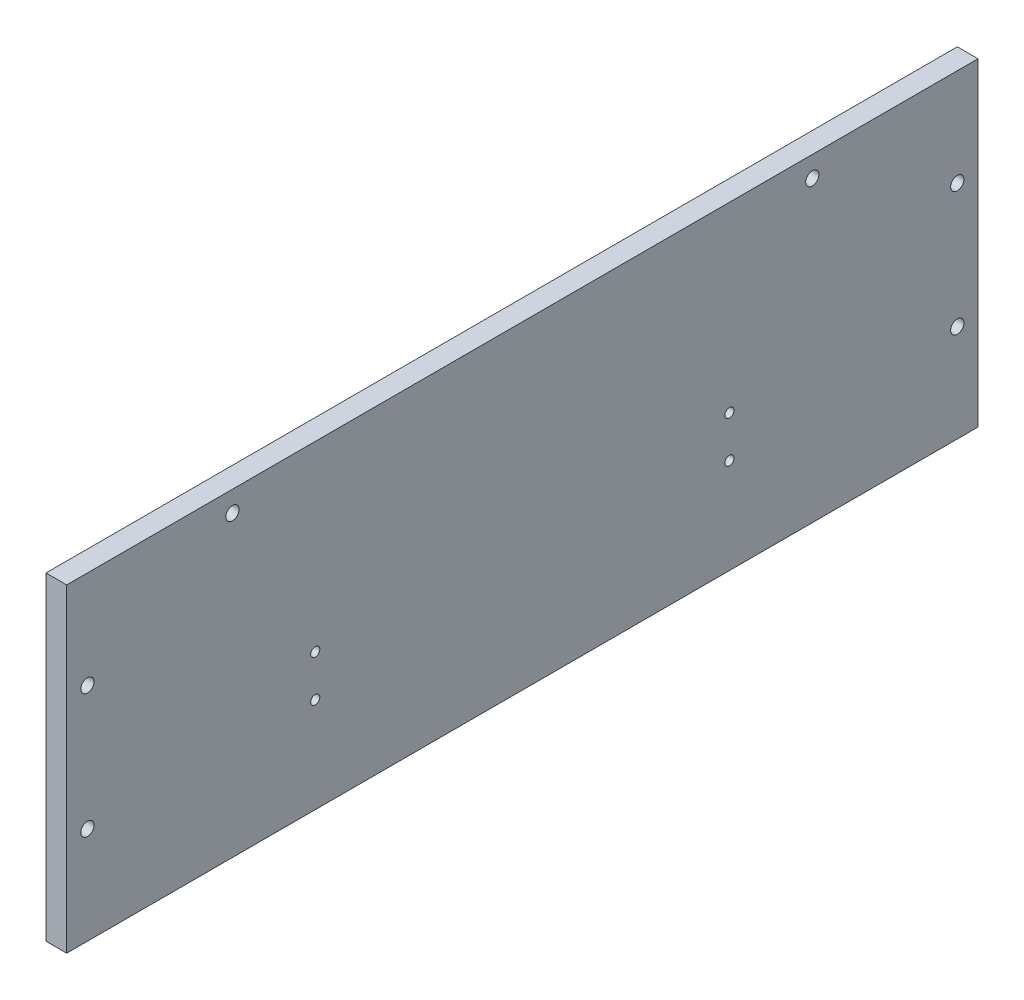
from build123d import *

# Parameters (mm, degrees)
SKETCH1_W                  = 5
SKETCH1_H                  = 110
BOSS_EXTRUDE1_DEPTH        = 120
BOSS_EXTRUDE1_DEPTH_BACK   = 110
BOSS_EXTRUDE1_2_DEPTH      = 120
BOSS_EXTRUDE1_2_DEPTH_BACK = 110
SKETCH2_W                  = 5
SKETCH2_H                  = 37
BOSS_EXTRUDE2_DEPTH        = 50
SKETCH3_W                  = 220
SKETCH3_H                  = 5
BOSS_EXTRUDE3_DEPTH        = 50
SKETCH4_W                  = 230
SKETCH4_H                  = 73
BOSS_EXTRUDE6_DEPTH        = 5
CUT_EXTRUDE3_DEPTH         = 231
SKETCH5_W                  = 348
SKETCH5_H                  = 227
SKETCH5_W_2                = 328
SKETCH5_H_2                = 207
BOSS_EXTRUDE7_DEPTH        = 5
BOSS_EXTRUDE8_DEPTH        = 59
FILLET5_R                  = 15
BOSS_EXTRUDE9_DEPTH        = 5
BOSS_EXTRUDE10_DEPTH       = 5
FILLET6_R                  = 3
SKETCH14_W                 = 102.087252512
SKETCH14_H                 = 394.36321675
CUT_EXTRUDE4_DEPTH         = 165.048773235
CUT_EXTRUDE7_DEPTH         = 6
SKETCH17_R                 = 1.1
HOLES_FOR_PART_4_DEPTH     = 6
SKETCH18_R                 = 1.6
CUT_EXTRUDE9_DEPTH         = 6


with BuildPart() as part:
    # Sketch1 → Boss-Extrude1 (new body, two sides)
    with BuildSketch(Plane(origin=(0, 0, 0), x_dir=(0, 0, -1), z_dir=(1, 0, 0))) as boss_extrude1_sk:
        with Locations((-112.5, 55)):
            Rectangle(SKETCH1_W, SKETCH1_H)
    extrude(amount=BOSS_EXTRUDE1_DEPTH)
    extrude(boss_extrude1_sk.sketch, amount=-BOSS_EXTRUDE1_DEPTH_BACK)



with BuildPart() as body_2:
    # Sketch1 → Boss-Extrude1 2 (new body, two sides)
    with BuildSketch(Plane(origin=(0, 0, 0), x_dir=(0, 0, -1), z_dir=(1, 0, 0))) as boss_extrude1_2_sk:
        with Locations((112.5, 55)):
            Rectangle(SKETCH1_W, SKETCH1_H)
    extrude(amount=BOSS_EXTRUDE1_2_DEPTH)
    extrude(boss_extrude1_2_sk.sketch, amount=-BOSS_EXTRUDE1_2_DEPTH_BACK)


with BuildPart() as part_1:
    add(part.part)

    add(body_2.part)  # Boss-Extrude2 merges body 2
    # Sketch2 → Boss-Extrude2 (add)
    with BuildSketch(Plane.ZY.offset(110)):
        with Locations((-112.5, 18.5)):
            Rectangle(SKETCH2_W, SKETCH2_H)
        with Locations((112.5, 18.5)):
            Rectangle(SKETCH2_W, SKETCH2_H)
    extrude(amount=BOSS_EXTRUDE2_DEPTH)

    # Sketch3 → Boss-Extrude3 (add)
    with BuildSketch(Plane.ZY.offset(160)):
        with Locations((0, 34.5)):
            Rectangle(SKETCH3_W, SKETCH3_H)
    extrude(amount=-BOSS_EXTRUDE3_DEPTH)

    # Sketch4 → Boss-Extrude6 (add)
    with BuildSketch(Plane.ZY.offset(110)):
        with Locations((0, 73.5)):
            Rectangle(SKETCH4_W, SKETCH4_H)
    extrude(amount=BOSS_EXTRUDE6_DEPTH)

    # Sketch9 → Cut-Extrude3 (cut, through all)
    with BuildSketch(Plane.XY.offset(115)):
        Polygon((120, 110), (116.464466094, 106.464466094), (120, 102.928932188), align=None)
    extrude(amount=-CUT_EXTRUDE3_DEPTH, mode=Mode.SUBTRACT)

    # Sketch10 → Boss-Extrude8 (add)
    with BuildSketch(Plane.XY.offset(115)):
        Polygon((120, 110), (111.464466094, 110), (111.464466094, 0), (120, 0), (120, 102.928932188), (116.464466094, 106.464466094), align=None)
    boss_extrude8 = extrude(amount=BOSS_EXTRUDE8_DEPTH)

    # Mirror3: Boss-Extrude8 across plane
    add(boss_extrude8.mirror(Plane.XY))

    # Fillet5
    fillet5_edges = [part_1.edges().sort_by_distance(p)[0] for p in [
        (111.464466094, 55, 115),
        (111.464466094, 55, -115),
    ]]
    fillet(fillet5_edges, radius=FILLET5_R)

    # Fillet6
    fillet6_edges = [part_1.edges().sort_by_distance(p)[0] for p in [
        (111.464466094, 55, 174),
        (111.464466094, 55, -174),
    ]]
    fillet(fillet6_edges, radius=FILLET6_R)


with BuildPart() as body_2_2:
    # Sketch5 → Boss-Extrude7 (new body)
    with BuildSketch(Plane(origin=(115, 115, 0), x_dir=(0, 0, 1), z_dir=(-0.707106781, -0.707106781, 0))):
        with Locations((0, -120.571067812)):
            Rectangle(SKETCH5_W, SKETCH5_H)
        with Locations((0, -120.571067812)):
            Rectangle(SKETCH5_W_2, SKETCH5_H_2, mode=Mode.SUBTRACT)
    extrude(amount=BOSS_EXTRUDE7_DEPTH)


with BuildPart() as body_3:
    # Sketch12 → Boss-Extrude9 (new body)
    with BuildSketch(Plane.XY.offset(174)):
        Polygon((120, 0), (222.928932188, 0), (120, 102.928932188), align=None)
    extrude(amount=-BOSS_EXTRUDE9_DEPTH)


with BuildPart() as body_4:
    # Sketch13 → Boss-Extrude10 (new body)
    with BuildSketch(Plane(origin=(0, 0, -174), x_dir=(-1, 0, 0), z_dir=(0, 0, -1))):
        Polygon((-120, 102.928932188), (-120, 0), (-222.928932188, 0), align=None)
    extrude(amount=-BOSS_EXTRUDE10_DEPTH)


with BuildPart() as cut_extrude4_tool:
    # Sketch14 → Cut-Extrude4 (new body, through all)
    with BuildSketch(Plane(origin=(0, 110, 0), x_dir=(1, 0, 0), z_dir=(0, 1, 0))):
        Polygon((-110, 193.761157723), (-110, -200.602059027), (365.223312192, -200.602059027), (365.223312192, -115), (365.223312192, 105), (365.223312192, 193.761157723), align=None)
        with Locations((-166.043626256, -3.420450652)):
            Rectangle(SKETCH14_W, SKETCH14_H)
    extrude(amount=-CUT_EXTRUDE4_DEPTH)


with BuildPart() as part_2:
    add(part_1.part)

    # Cut-Extrude4: cut by cut_extrude4_tool
    add(cut_extrude4_tool.part, mode=Mode.SUBTRACT)

    # Sketch16 → Cut-Extrude7 (cut, through all)
    with BuildSketch(Plane.ZY.offset(115)):
        Polygon((-115, 0), (115, 0), (115, 32), (115, 110), (110, 110), (110, 33), (-110, 33), (-110, 110), (-115, 110), (-115, 32), align=None)
    extrude(amount=-CUT_EXTRUDE7_DEPTH, mode=Mode.SUBTRACT)

    # Sketch17 → Holes for part 4 (cut, through all)
    with BuildSketch(Plane.ZY.offset(115)):
        with Locations((50, 66)):
            Circle(SKETCH17_R)
        with Locations((50, 56)):
            Circle(SKETCH17_R)
        with Locations((-50, 56)):
            Circle(SKETCH17_R)
        with Locations((-50, 66)):
            Circle(SKETCH17_R)
    extrude(amount=-HOLES_FOR_PART_4_DEPTH, mode=Mode.SUBTRACT)

    # Sketch18 → Cut-Extrude9 (cut, through all)
    with BuildSketch(Plane.ZY.offset(115)):
        with Locations((105, 56.5)):
            Circle(SKETCH18_R)
        with Locations((105, 86.5)):
            Circle(SKETCH18_R)
        with Locations((-105, 86.5)):
            Circle(SKETCH18_R)
        with Locations((-105, 56.5)):
            Circle(SKETCH18_R)
        with Locations((70, 105)):
            Circle(SKETCH18_R)
        with Locations((-70, 105)):
            Circle(SKETCH18_R)
    extrude(amount=-CUT_EXTRUDE9_DEPTH, mode=Mode.SUBTRACT)


with BuildPart() as body_2_2_1:
    add(body_2_2.part)

    # Cut-Extrude4: cut by cut_extrude4_tool
    add(cut_extrude4_tool.part, mode=Mode.SUBTRACT)


with BuildPart() as body_3_1:
    add(body_3.part)

    # Cut-Extrude4: cut by cut_extrude4_tool
    add(cut_extrude4_tool.part, mode=Mode.SUBTRACT)


with BuildPart() as body_4_1:
    add(body_4.part)

    # Cut-Extrude4: cut by cut_extrude4_tool
    add(cut_extrude4_tool.part, mode=Mode.SUBTRACT)


solid = part_2.part
